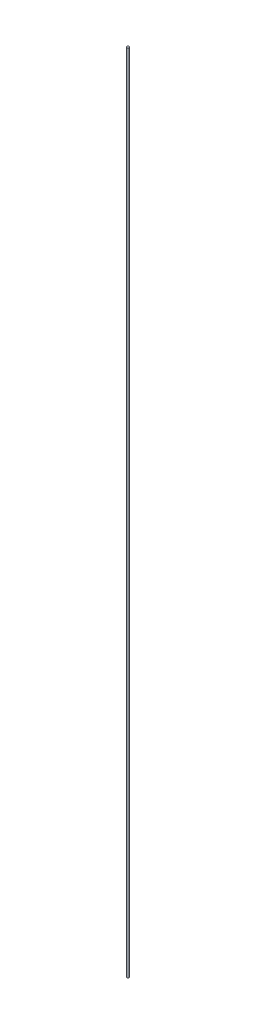
from build123d import *

# Parameters (mm, degrees)
SKETCH1_R           = 0.75
BOSS_EXTRUDE1_DEPTH = 491


with BuildPart() as part:
    # Sketch1 → Boss-Extrude1 (new body)
    with BuildSketch(Plane(origin=(0, 0, 0), x_dir=(1, 0, 0), z_dir=(0, 1, 0))):
        Circle(SKETCH1_R)
    extrude(amount=BOSS_EXTRUDE1_DEPTH)


solid = part.part
